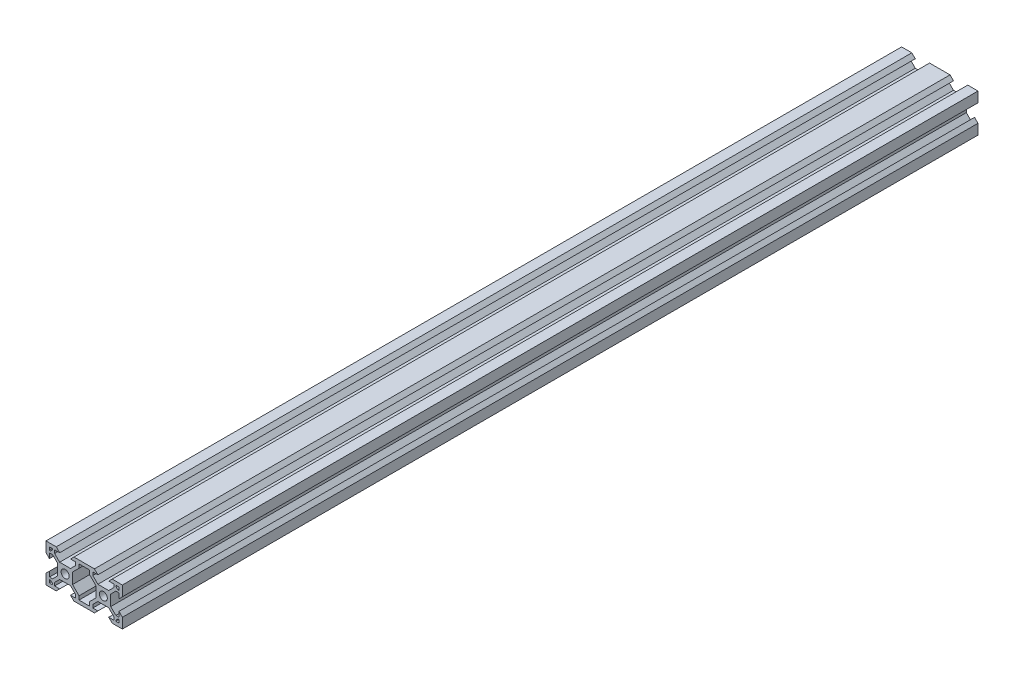
from build123d import *

# Parameters (mm, degrees)
SKETCH1_R           = 2.1
BOSS_EXTRUDE1_DEPTH = 448


with BuildPart() as part:
    # Sketch1 → Boss-Extrude1 (new body)
    with BuildSketch(Plane.XY):
        Polygon((0, 0), (0, 5.36), (1.8, 7.16), (1.8, 4.500660172), (3.44, 4.500660172), (6.099339828, 7.16), (6.099339828, 12.84), (3.44, 15.499339828), (1.8, 15.499339828), (1.8, 12.84), (0, 14.64), (0, 20), (5.36, 20), (7.16, 18.2), (4.500660172, 18.2), (4.500660172, 16.56), (7.16, 13.900660172), (12.84, 13.900660172), (15.499339828, 16.56), (15.499339828, 18.2), (12.84, 18.2), (14.64, 20), (20, 20), (25.36, 20), (27.16, 18.2), (24.500939946, 18.2), (24.50125838, 16.559689577), (27.161114417, 13.900866058), (32.84111431, 13.901968719), (35.499937829, 16.561824756), (35.49961981, 18.2), (32.84, 18.2), (34.64, 20), (39.999930631, 20), (40.000970647, 14.642698508), (38.201320116, 12.842349107), (38.200803857, 15.501688885), (36.560803888, 15.501370511), (33.901980368, 12.841514474), (33.903083029, 7.161514581), (36.562939066, 4.502691062), (38.202939036, 4.503009436), (38.202422777, 7.162349214), (40.002772178, 5.362698683), (40.003813241, 0), (34.64, 0), (32.84, 1.8), (35.502803549, 1.8), (35.502484821, 3.441825004), (32.842628784, 6.100648523), (27.162628891, 6.099545862), (24.503805372, 3.439689825), (24.504123686, 1.8), (27.16, 1.8), (25.36, 0), (20, 0), (14.64, 0), (12.84, 1.8), (15.499339828, 1.8), (15.499339828, 3.44), (12.84, 6.099339828), (7.16, 6.099339828), (4.500660172, 3.44), (4.500660172, 1.8), (7.16, 1.8), (5.36, 0), align=None)
        with Locations((10, 10)):
            Circle(SKETCH1_R, mode=Mode.SUBTRACT)
        with Locations((30, 10)):
            Circle(SKETCH1_R, mode=Mode.SUBTRACT)
        Polygon((17.300660172, 3.76), (17.300660172, 1.8), (22.700660172, 1.8), (22.700660172, 3.76), (26.100660172, 7.16), (26.100660172, 12.84), (22.699339828, 16.24), (22.699339828, 18.2), (17.300660172, 18.2), (17.300660172, 16.24), (13.900660172, 12.84), (13.900660172, 7.16), align=None, mode=Mode.SUBTRACT)
        Polygon((1.8, 18.2), (3.430660172, 18.2), (3.430660172, 17.63), (2.37, 16.569339828), (1.8, 16.569339828), align=None, mode=Mode.SUBTRACT)
        Polygon((1.8, 3.430660172), (1.8, 1.8), (3.430660172, 1.8), (3.430660172, 2.37), (2.37, 3.430660172), align=None, mode=Mode.SUBTRACT)
        Polygon((38.2, 1.8), (36.569339828, 1.8), (36.569339828, 2.37), (37.63, 3.430660172), (38.2, 3.430660172), align=None, mode=Mode.SUBTRACT)
        Polygon((38.2, 16.569339828), (38.2, 18.2), (36.569339828, 18.2), (36.569339828, 17.63), (37.63, 16.569339828), align=None, mode=Mode.SUBTRACT)
    extrude(amount=-BOSS_EXTRUDE1_DEPTH)


solid = part.part
